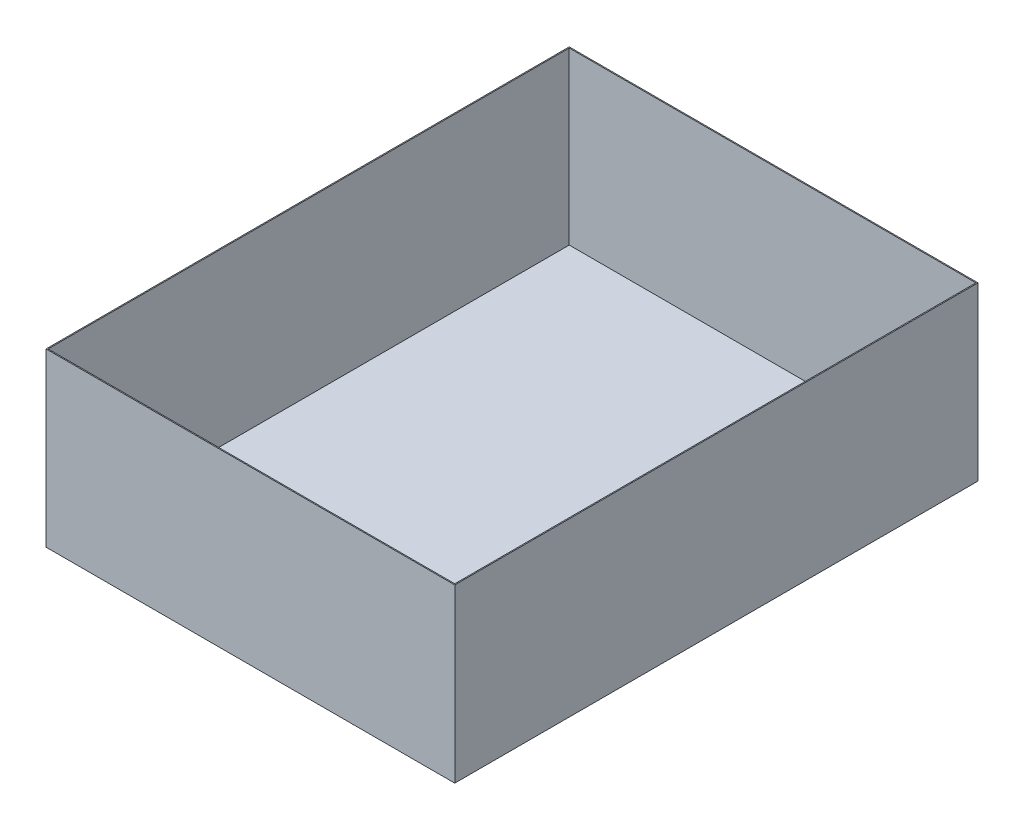
from build123d import *

# Parameters (mm, degrees)
SKETCH1_W           = 250
SKETCH1_H           = 320
BOSS_EXTRUDE5_DEPTH = 105
SHELL2_T            = -0.635


with BuildPart() as part:
    # Sketch1 → Boss-Extrude5 (new body)
    with BuildSketch(Plane(origin=(0, 0, 0), x_dir=(1, 0, 0), z_dir=(0, 1, 0))):
        with Locations((125, 160)):
            Rectangle(SKETCH1_W, SKETCH1_H)
    extrude(amount=-BOSS_EXTRUDE5_DEPTH)

    # Shell2
    shell2_openings = [part.faces().sort_by_distance(p)[0] for p in [
        (125, 0, -160),
    ]]
    offset(amount=SHELL2_T, openings=shell2_openings, kind=Kind.INTERSECTION)


solid = part.part
